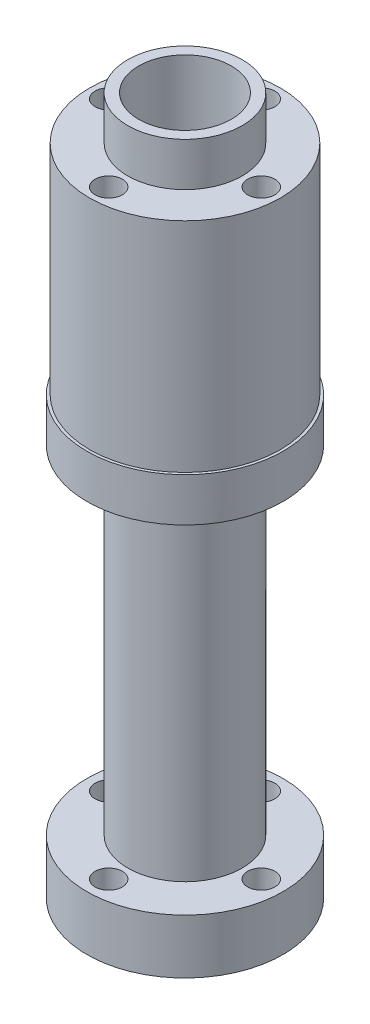
from build123d import *

# Parameters (mm, degrees)
SKETCH_2_R          = 1.25
CUT_EXTRUDE_1_DEPTH = 10
CUT_EXTRUDE_START   = -60
SKETCH_2_2_R        = 1.25
CUT_EXTRUDE_2_DEPTH = 6
SKETCH_3_OUTSIDE_W  = 33.036
SKETCH_3_OUTSIDE_H  = 33.036
SKETCH_3_OUTSIDE_R  = 8.75
CUT_EXTRUDE_3_DEPTH = 20
SKETCH_4_R          = 5.25
SKETCH_4_R_2        = 4.25
EXTRUDE_1_DEPTH     = 4


with BuildPart() as part:
    # 草图1 → 旋转1 (revolve)
    with BuildSketch(Plane.XY, mode=Mode.PRIVATE) as revolve_1_sk:
        Polygon((-9, 36), (-5.25, 36), (-5.25, 5), (-9, 5), (-9, 0), (-4.25, 0), (-4.25, 60), (-9, 60), align=None)
    revolve(revolve_1_sk.sketch.rotate(Axis((0, 0, 0), (0, 1, 0)), 270), axis=Axis((0, 0, 0), (0, 1, 0)))

    # 草图2 → 切除-拉伸1 (cut)
    with BuildSketch(Plane(origin=(0, 60, 0), x_dir=(1, 0, 0), z_dir=(0, 1, 0))):
        with Locations(Location((0, 7, 0), (0, 0, 270))):
            Circle(SKETCH_2_R)
        with Locations(Location((0, -7, 0), (0, 0, 270))):
            Circle(SKETCH_2_R)
        with Locations(Location((-7, 0, 0), (0, 0, 270))):
            Circle(SKETCH_2_R)
        with Locations(Location((7, 0, 0), (0, 0, 270))):
            Circle(SKETCH_2_R)
    extrude(amount=-CUT_EXTRUDE_1_DEPTH, mode=Mode.SUBTRACT)

    # 草图2<2> → 切除-拉伸2 (cut)
    with BuildSketch(Plane(origin=(0, 60, 0), x_dir=(1, 0, 0), z_dir=(0, 1, 0)).offset(CUT_EXTRUDE_START)):
        with Locations(Location((0, 7, 0), (0, 0, 270))):
            Circle(SKETCH_2_2_R)
        with Locations(Location((0, -7, 0), (0, 0, 270))):
            Circle(SKETCH_2_2_R)
        with Locations(Location((-7, 0, 0), (0, 0, 270))):
            Circle(SKETCH_2_2_R)
        with Locations(Location((7, 0, 0), (0, 0, 270))):
            Circle(SKETCH_2_2_R)
    extrude(amount=CUT_EXTRUDE_2_DEPTH, mode=Mode.SUBTRACT)

    # 草图3 outside → 切除-拉伸3 (cut)
    with BuildSketch(Plane(origin=(0, 60, 0), x_dir=(1, 0, 0), z_dir=(0, 1, 0))):
        Rectangle(SKETCH_3_OUTSIDE_W, SKETCH_3_OUTSIDE_H)
        with Locations(Location((0, 0, 0), (0, 0, 270))):
            Circle(SKETCH_3_OUTSIDE_R, mode=Mode.SUBTRACT)
    extrude(amount=-CUT_EXTRUDE_3_DEPTH, mode=Mode.SUBTRACT)

    # 草图4 → 凸台-拉伸1 (add)
    with BuildSketch(Plane(origin=(0, 60, 0), x_dir=(1, 0, 0), z_dir=(0, 1, 0))):
        with Locations(Location((0, 0, 0), (0, 0, 90))):
            Circle(SKETCH_4_R)
        with Locations(Location((0, 0, 0), (0, 0, 90))):
            Circle(SKETCH_4_R_2, mode=Mode.SUBTRACT)
    extrude(amount=EXTRUDE_1_DEPTH)


solid = part.part
